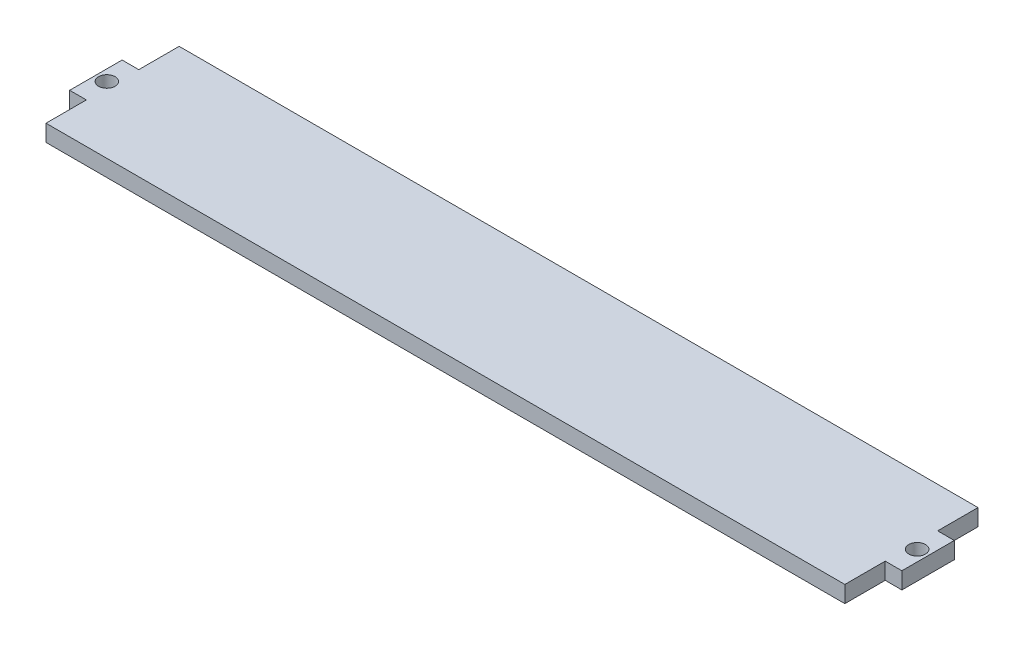
from build123d import *

# Parameters (mm, degrees)
SKETCH2_W           = 152.4
SKETCH2_H           = 25.4
BOSS_EXTRUDE1_DEPTH = 3.18
SKETCH3_W           = 10
SKETCH3_H           = 3.18
BOSS_EXTRUDE2_DEPTH = 3.18
SKETCH4_W           = 10
SKETCH4_H           = 3.18
BOSS_EXTRUDE3_DEPTH = 3.18
SKETCH5_R           = 1.59
CUT_EXTRUDE1_DEPTH  = 3.18


with BuildPart() as part:
    # Sketch2 → Boss-Extrude1 (new body)
    with BuildSketch(Plane(origin=(0, 0, 0), x_dir=(1, 0, 0), z_dir=(0, 1, 0))):
        Rectangle(SKETCH2_W, SKETCH2_H)
    extrude(amount=BOSS_EXTRUDE1_DEPTH)

    # Sketch3 → Boss-Extrude2 (add)
    with BuildSketch(Plane.ZY.offset(76.2)):
        with Locations((0, 1.59)):
            Rectangle(SKETCH3_W, SKETCH3_H)
    extrude(amount=BOSS_EXTRUDE2_DEPTH)

    # Sketch4 → Boss-Extrude3 (add)
    with BuildSketch(Plane(origin=(76.2, 0, 0), x_dir=(0, 0, -1), z_dir=(1, 0, 0))):
        with Locations((0, 1.59)):
            Rectangle(SKETCH4_W, SKETCH4_H)
    extrude(amount=BOSS_EXTRUDE3_DEPTH)

    # Sketch5 → Cut-Extrude1 (cut)
    with BuildSketch(Plane(origin=(0, 3.18, 0), x_dir=(1, 0, 0), z_dir=(0, 1, 0))):
        with Locations((77.29, 0)):
            Circle(SKETCH5_R)
        with Locations((-77.29, 0)):
            Circle(SKETCH5_R)
    extrude(amount=-CUT_EXTRUDE1_DEPTH, mode=Mode.SUBTRACT)


solid = part.part
